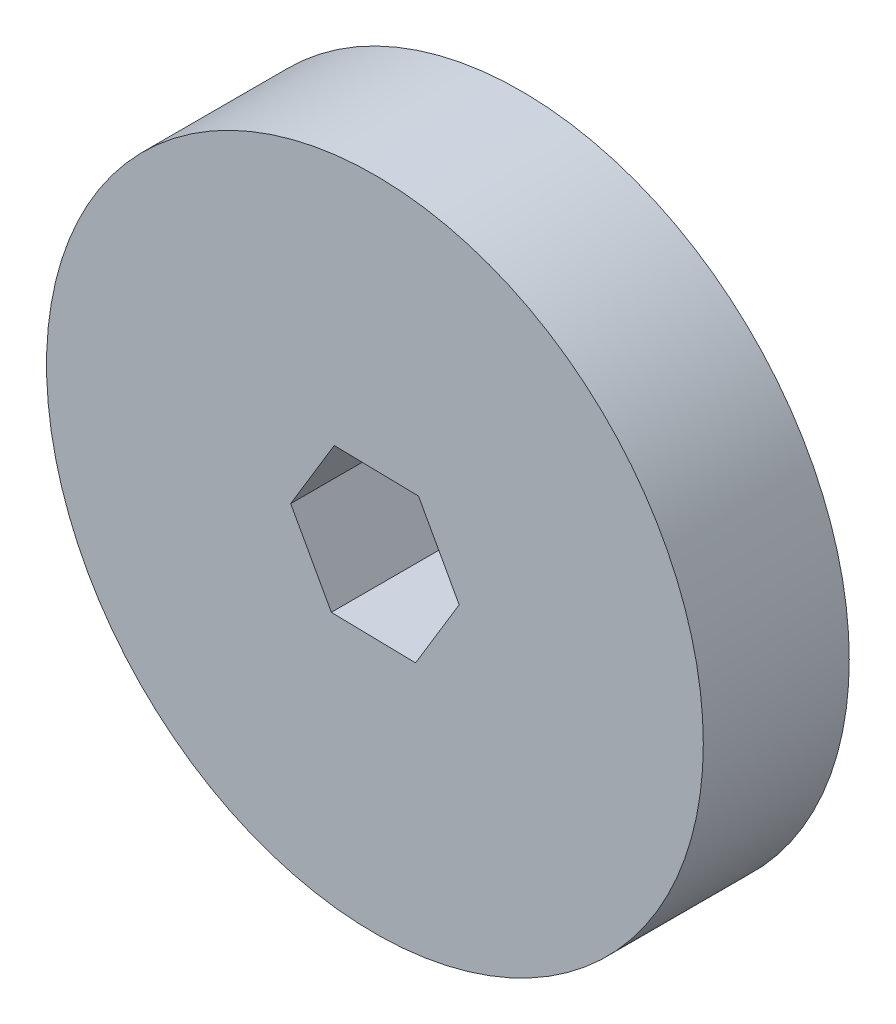
from build123d import *

# Parameters (mm, degrees)
SKETCH1_R           = 28.575
BOSS_EXTRUDE1_DEPTH = 12.7


with BuildPart() as part:
    # Sketch1 → Boss-Extrude1 (new body)
    with BuildSketch(Plane.XY):
        Circle(SKETCH1_R)
        Polygon((3.538168309, -6.422203543), (7.330875571, -0.146958133), (3.792707262, 6.27524541), (-3.538168309, 6.422203543), (-7.330875571, 0.146958133), (-3.792707262, -6.27524541), align=None, mode=Mode.SUBTRACT)
    extrude(amount=BOSS_EXTRUDE1_DEPTH)


solid = part.part
